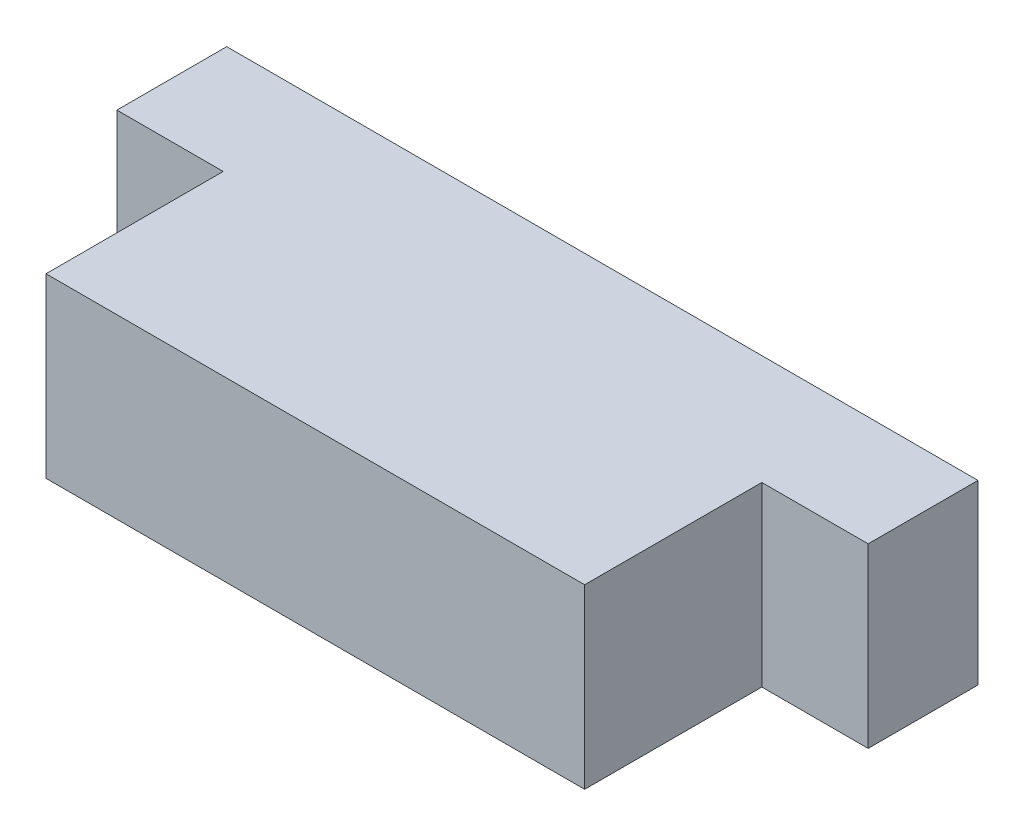
from build123d import *

# Parameters (mm, degrees)
EXTRUDE_2_DEPTH = 5


with BuildPart() as part:
    # 草图2 → 凸台-拉伸2 (new body)
    with BuildSketch(Plane(origin=(0, 0, 0), x_dir=(1, 0, 0), z_dir=(0, 1, 0))):
        Polygon((0, 0), (0, 5), (-3, 5), (-3, 8.1), (18.2, 8.1), (18.2, 5), (15.2, 5), (15.2, 0), align=None)
    extrude(amount=EXTRUDE_2_DEPTH)


solid = part.part
